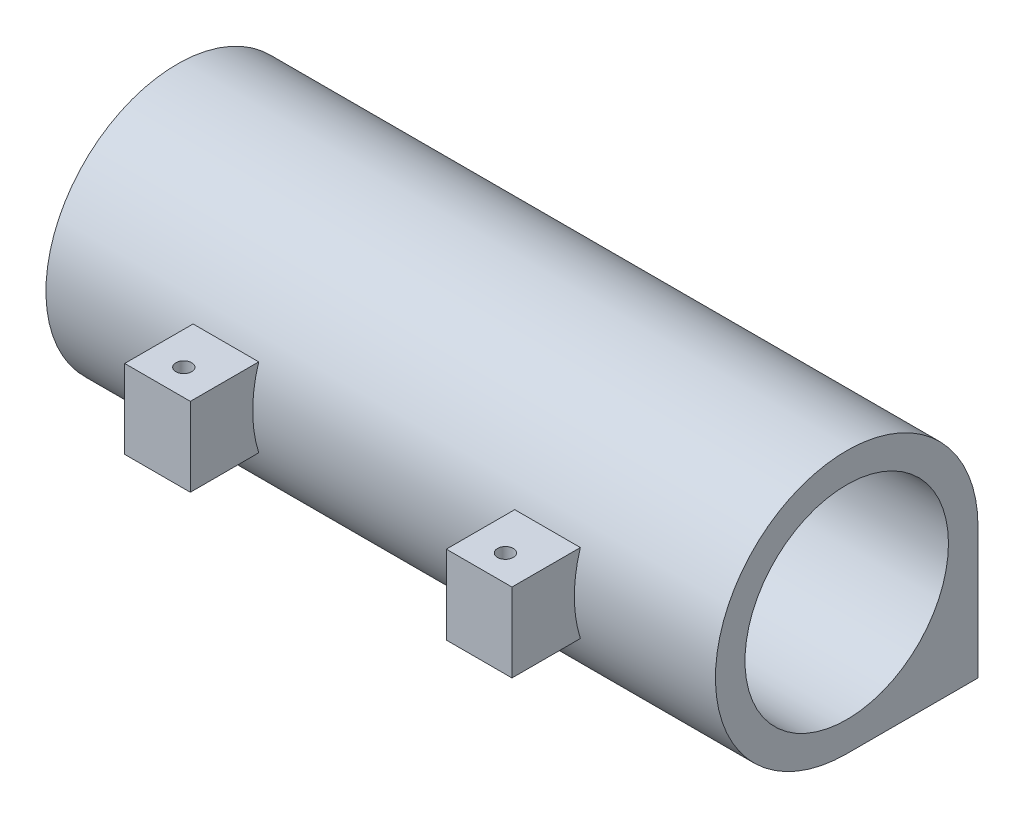
from build123d import *
from build123d.topology import SkipClean

# Parameters (mm, degrees)
SKETCH1_W                = 34
SKETCH1_H                = 30
BOSS_EXTRUDE2_DEPTH      = 51
SKETCH3_R                = 2.55
CUT_EXTRUDE3_DEPTH       = 10
SKETCH5_R                = 7.75
CUT_EXTRUDE4_DEPTH       = 51
SKETCH6_W                = 7
SKETCH6_H                = 30
CUT_EXTRUDE6_DEPTH       = 51
CUT_EXTRUDE7_DEPTH       = 51
CUT_EXTRUDE9_DEPTH       = 1.5
CUT_EXTRUDE9_DEPTH_BACK  = 1.5
BOSS_EXTRUDE5_DEPTH      = 51
CUT_EXTRUDE10_DEPTH      = 13
CUT_EXTRUDE11_START      = -13
CUT_EXTRUDE11_DEPTH      = 13
SKETCH13_W               = 2
SKETCH13_H               = 6
CUT_EXTRUDE12_DEPTH      = 2
CUT_EXTRUDE13_DEPTH      = 13
CUT_EXTRUDE13_DEPTH_BACK = 11
BOSS_EXTRUDE6_DEPTH      = 2.25
BOSS_EXTRUDE7_DEPTH      = 2.25
BOSS_EXTRUDE8_DEPTH      = 2.25
BOSS_EXTRUDE9_DEPTH      = 2.25
SKETCH22_W               = 5
SKETCH22_H               = 6
BOSS_EXTRUDE10_DEPTH     = 1
SKETCH24_W               = 5
SKETCH24_H               = 6
BOSS_EXTRUDE11_DEPTH     = 1
SKETCH25_R               = 0.6
CUT_EXTRUDE14_DEPTH      = 20


with BuildPart() as part:
    # Sketch1 → Boss-Extrude2 (new body)
    with BuildSketch(Plane(origin=(0, 0, 0), x_dir=(0, 0, -1), z_dir=(1, 0, 0))):
        with Locations((-3.945183177, 6.145902028)):
            Rectangle(SKETCH1_W, SKETCH1_H)
    extrude(amount=BOSS_EXTRUDE2_DEPTH)

    # Sketch3 → Cut-Extrude3 (cut)
    with BuildSketch(Plane(origin=(0, 0, -13.054816823), x_dir=(-1, 0, 0), z_dir=(0, 0, -1))):
        with Locations((-25.5, -1.354097972)):
            Circle(SKETCH3_R)
    extrude(amount=-CUT_EXTRUDE3_DEPTH, mode=Mode.SUBTRACT)

    # Sketch5 → Cut-Extrude4 (cut)
    with BuildSketch(Plane(origin=(51, 0, 0), x_dir=(0, 0, -1), z_dir=(1, 0, 0))):
        with Locations((-3.945183177, 1.145902028)):
            Circle(SKETCH5_R)
    extrude(amount=-CUT_EXTRUDE4_DEPTH, mode=Mode.SUBTRACT)

    # Sketch6 → Cut-Extrude6 (cut)
    with BuildSketch(Plane(origin=(51, 0, 0), x_dir=(0, 0, -1), z_dir=(1, 0, 0))):
        with Locations((9.554816823, 6.145902028)):
            Rectangle(SKETCH6_W, SKETCH6_H)
    extrude(amount=-CUT_EXTRUDE6_DEPTH, mode=Mode.SUBTRACT)

    # Sketch7 → Cut-Extrude7 (cut)
    with BuildSketch(Plane(origin=(51, 0, 0), x_dir=(0, 0, -1), z_dir=(1, 0, 0))):
        with BuildLine():
            Line((-3.945183177, -8.854097972), (-20.945183177, -8.854097972))
            Line((-20.945183177, -8.854097972), (-20.945183177, 21.145902028))
            Line((-20.945183177, 21.145902028), (6.054816823, 21.145902028))
            Line((6.054816823, 21.145902028), (6.054816823, 1.145902028))
            ThreePointArc((6.054816823, 1.145902028), (-11.016250989, 8.21696984), (-3.945183177, -8.854097972))
        make_face()
    extrude(amount=-CUT_EXTRUDE7_DEPTH, mode=Mode.SUBTRACT)

    # Sketch8 → Cut-Extrude9 (cut, two sides: drawn at the far end of the back side and taken through both)
    with BuildSketch(Plane(origin=(0, 0, -3.054816823), x_dir=(-1, 0, 0), z_dir=(0, 0, -1)).offset(-CUT_EXTRUDE9_DEPTH_BACK)):
        Polygon((-21.75, -2.180131646), (-21.75, -4.904097972), (-29.25, -4.904097972), (-29.25, -2.180131646), (-29.25, 2.195902028), (-21.75, 2.195902028), align=None)
    extrude(amount=CUT_EXTRUDE9_DEPTH + CUT_EXTRUDE9_DEPTH_BACK, mode=Mode.SUBTRACT)

    # Sketch10 → Boss-Extrude5 (add)
    with BuildSketch(Plane(origin=(51, 0, 0), x_dir=(0, 0, -1), z_dir=(1, 0, 0))):
        Polygon((-17.695183177, 1.145902028), (-17.695183177, 4.145902028), (-11.695183177, 4.145902028), (-11.695183177, 1.145902028), (-11.695183177, -1.854097972), (-17.695183177, -1.854097972), align=None)
    extrude(amount=-BOSS_EXTRUDE5_DEPTH)

    # Sketch11 → Cut-Extrude10 (cut)
    with BuildSketch(Plane(origin=(51, 0, 0), x_dir=(0, 0, -1), z_dir=(1, 0, 0))):
        with BuildLine():
            Line((-13.484575191, -1.854097972), (-17.695183177, -1.854097972))
            Line((-17.695183177, -1.854097972), (-17.695183177, 4.145902028))
            Line((-17.695183177, 4.145902028), (-13.484575191, 4.145902028))
            ThreePointArc((-13.484575191, 4.145902028), (-13.945183177, 1.145902028), (-13.484575191, -1.854097972))
        make_face()
    extrude(amount=-CUT_EXTRUDE10_DEPTH, mode=Mode.SUBTRACT)

    # Sketch12 → Cut-Extrude11 (cut)
    with BuildSketch(Plane.ZY.offset(CUT_EXTRUDE11_START)):
        with BuildLine():
            Line((13.484575191, -1.854097972), (17.695183177, -1.854097972))
            Line((17.695183177, -1.854097972), (17.695183177, 4.145902028))
            Line((17.695183177, 4.145902028), (13.484575191, 4.145902028))
            ThreePointArc((13.484575191, 4.145902028), (13.945183177, 1.145902028), (13.484575191, -1.854097972))
        make_face()
    extrude(amount=CUT_EXTRUDE11_DEPTH, mode=Mode.SUBTRACT)

    # Sketch13 → Cut-Extrude12 (cut)
    with BuildSketch(Plane.XY.offset(17.695183177)):
        with Locations((25.5, 1.145902028)):
            Rectangle(SKETCH13_W, SKETCH13_H)
    extrude(amount=-CUT_EXTRUDE12_DEPTH, mode=Mode.SUBTRACT)

    # Sketch15 → Cut-Extrude13 (cut, two sides: drawn at the far end of the back side and taken through both)
    with SkipClean():  # the faces are left unmerged after this step: merging them gives an invalid solid
        with BuildSketch(Plane(origin=(24.5, 0, 0), x_dir=(0, 0, -1), z_dir=(1, 0, 0)).offset(-CUT_EXTRUDE13_DEPTH_BACK)):
            with BuildLine():
                Line((-17.695183177, 4.145902028), (-17.695183177, -1.854097972))
                Line((-17.695183177, -1.854097972), (-13.484575191, -1.854097972))
                ThreePointArc((-13.484575191, -1.854097972), (-13.945183177, 1.145902028), (-13.484575191, 4.145902028))
                Line((-13.484575191, 4.145902028), (-17.695183177, 4.145902028))
            make_face()
        extrude(amount=CUT_EXTRUDE13_DEPTH + CUT_EXTRUDE13_DEPTH_BACK, mode=Mode.SUBTRACT)

    # Sketch17 → Boss-Extrude6 (add)
    with SkipClean():  # the faces are left unmerged after this step: merging them gives an invalid solid
        with BuildSketch(Plane(origin=(38, 0, 0), x_dir=(0, 0, -1), z_dir=(1, 0, 0))):
            with BuildLine():
                Line((-13.484575191, 4.145902028), (-17.695183177, 4.145902028))
                Line((-17.695183177, 4.145902028), (-17.695183177, -1.854097972))
                Line((-17.695183177, -1.854097972), (-13.484575191, -1.854097972))
                ThreePointArc((-13.484575191, -1.854097972), (-13.945183177, 1.145902028), (-13.484575191, 4.145902028))
            make_face()
        extrude(amount=BOSS_EXTRUDE6_DEPTH)

    # Sketch19 → Boss-Extrude7 (add)
    with SkipClean():  # the faces are left unmerged after this step: merging them gives an invalid solid
        with BuildSketch(Plane.ZY.offset(-13)):
            with BuildLine():
                Line((13.484575191, 4.145902028), (17.695183177, 4.145902028))
                Line((17.695183177, 4.145902028), (17.695183177, -1.854097972))
                Line((17.695183177, -1.854097972), (13.484575191, -1.854097972))
                ThreePointArc((13.484575191, -1.854097972), (13.945183177, 1.145902028), (13.484575191, 4.145902028))
            make_face()
        extrude(amount=BOSS_EXTRUDE7_DEPTH)

    # Sketch20 → Boss-Extrude8 (add)
    with SkipClean():  # the faces are left unmerged after this step: merging them gives an invalid solid
        with BuildSketch(Plane(origin=(13.5, 0, 0), x_dir=(0, 0, -1), z_dir=(1, 0, 0))):
            with BuildLine():
                Line((-17.695183177, -1.854097972), (-17.695183177, 4.145902028))
                Line((-17.695183177, 4.145902028), (-13.484575191, 4.145902028))
                ThreePointArc((-13.484575191, 4.145902028), (-13.945183177, 1.145902028), (-13.484575191, -1.854097972))
                Line((-13.484575191, -1.854097972), (-17.695183177, -1.854097972))
            make_face()
        extrude(amount=BOSS_EXTRUDE8_DEPTH)

    # Sketch21 → Boss-Extrude9 (add)
    with SkipClean():  # the faces are left unmerged after this step: merging them gives an invalid solid
        with BuildSketch(Plane.ZY.offset(-37.5)):
            with BuildLine():
                Line((13.484575191, 4.145902028), (17.695183177, 4.145902028))
                Line((17.695183177, 4.145902028), (17.695183177, -1.854097972))
                Line((17.695183177, -1.854097972), (13.484575191, -1.854097972))
                ThreePointArc((13.484575191, -1.854097972), (13.945183177, 1.145902028), (13.484575191, 4.145902028))
            make_face()
        extrude(amount=BOSS_EXTRUDE9_DEPTH)

    # Sketch22 → Boss-Extrude10 (add)
    with SkipClean():  # the faces are left unmerged after this step: merging them gives an invalid solid
        with BuildSketch(Plane.XY.offset(17.695183177)):
            with Locations((37.75, 1.145902028)):
                Rectangle(SKETCH22_W, SKETCH22_H)
        extrude(amount=BOSS_EXTRUDE10_DEPTH)

    # Sketch24 → Boss-Extrude11 (add)
    with SkipClean():  # the faces are left unmerged after this step: merging them gives an invalid solid
        with BuildSketch(Plane.XY.offset(17.695183177)):
            with Locations((13.25, 1.145902028)):
                Rectangle(SKETCH24_W, SKETCH24_H)
        extrude(amount=BOSS_EXTRUDE11_DEPTH)

    # Sketch25 → Cut-Extrude14 (cut)
    with SkipClean():  # the faces are left unmerged after this step: merging them gives an invalid solid
        with BuildSketch(Plane(origin=(0, 4.145902028, 0), x_dir=(1, 0, 0), z_dir=(0, 1, 0))):
            with Locations((13.25, -16.695183177)):
                Circle(SKETCH25_R)
            with Locations((37.75, -16.695183177)):
                Circle(SKETCH25_R)
        extrude(amount=-CUT_EXTRUDE14_DEPTH, mode=Mode.SUBTRACT)


solid = part.part
